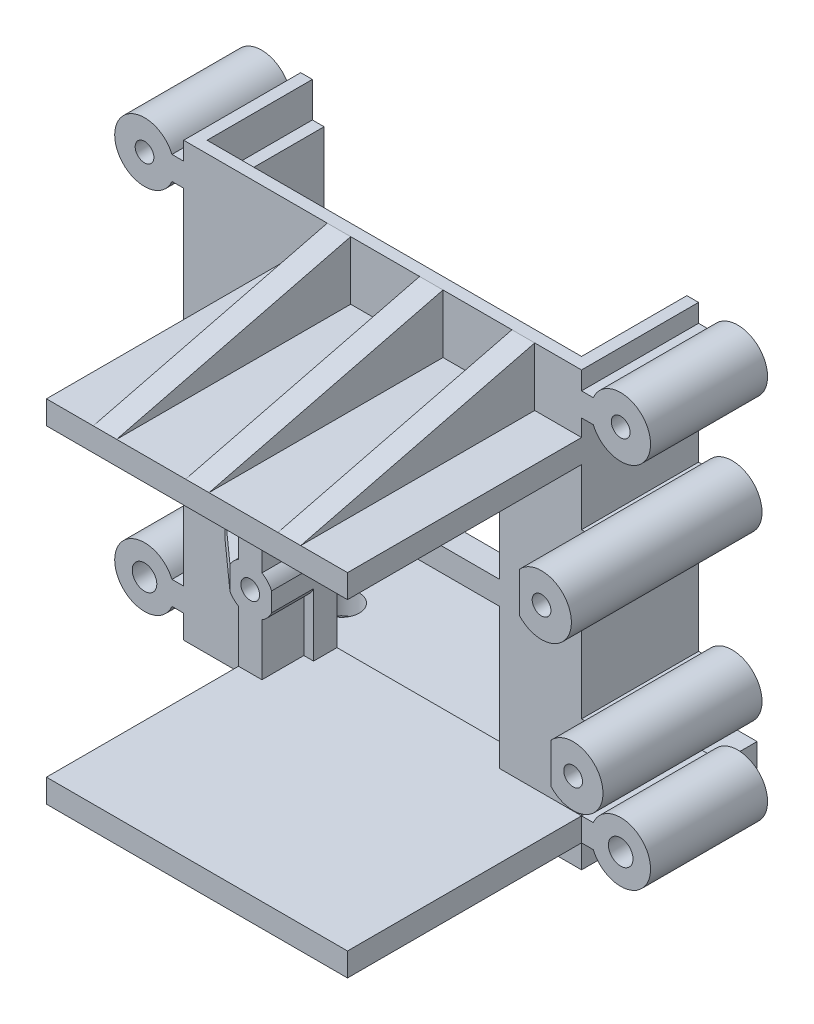
from build123d import *

# Parameters (mm, degrees)
ESQUISSE1_W              = 34
ESQUISSE1_H              = 15
BOSS_EXTRU_1_DEPTH       = 2
ESQUISSE2_R              = 1.5
ENL_V_MAT_EXTRU_1_DEPTH  = 2
BOSS_EXTRU_2_DEPTH       = 35
ENL_V_MAT_EXTRU_2_DEPTH  = 3
ESQUISSE5_R              = 3.5
ESQUISSE5_R_2            = 2
BOSS_EXTRU_3_DEPTH       = 3
ENL_V_START              = -2
ESQUISSE6_W              = 14
ESQUISSE6_H              = 12
ENL_V_MAT_EXTRU_3_DEPTH  = 2
ESQUISSE7_W              = 14
ESQUISSE7_H              = 12
ENL_V_MAT_EXTRU_4_DEPTH  = 2
ESQUISSE8_W              = 3
ESQUISSE8_H              = 12
ENL_V_MAT_EXTRU_5_DEPTH  = 2
BOSS_EXTRU_4_START       = -2
ESQUISSE9_W              = 1.1
ESQUISSE9_H              = 12
BOSS_EXTRU_4_DEPTH       = 2
ESQUISSE10_R             = 0.8
BOSS_EXTRU_5_DEPTH       = 6.285817
ESQUISSE11_R             = 0.8
BOSS_EXTRU_6_DEPTH       = 3.585817
ESQUISSE21_W             = 4
ESQUISSE21_H             = 2
BOSS_EXTRU_12_DEPTH      = 6.285817
ENL_V_MAT_EXTRU_9_DEPTH  = 2
ESQUISSE23_W             = 4
ESQUISSE23_H             = 2
BOSS_EXTRU_13_DEPTH      = 3.585817
ENL_V_MAT_EXTRU_10_DEPTH = 2
ESQUISSE25_W             = 2
ESQUISSE25_H             = 4.092832792
ESQUISSE25_H_2           = 4.443065592
BOSS_EXTRU_14_DEPTH      = 3.585817
ESQUISSE27_W             = 2
ESQUISSE27_H             = 4.092832792
ESQUISSE27_H_2           = 4
BOSS_EXTRU_15_DEPTH      = 6.285817
BOSS_EXTRU_17_START      = -10
ESQUISSE31_R             = 1.05
BOSS_EXTRU_17_DEPTH      = 10
BOSS_EXTRU_18_START      = -10
ESQUISSE33_R             = 0.8
BOSS_EXTRU_18_DEPTH      = 10
ESQUISSE34_R             = 0.8
BOSS_EXTRU_19_DEPTH      = 16.290743
ESQUISSE35_R             = 0.8
BOSS_EXTRU_20_DEPTH      = 13.590743
BOSS_EXTRU_21_DEPTH      = 20
ENL_V_START_2            = -17.727203
ENL_V_MAT_EXTRU_14_DEPTH = 17.727203
BOSS_EXTRU_23_START      = -2
ESQUISSE39_W             = 3.585817331
ESQUISSE39_H             = 2.443065592
BOSS_EXTRU_23_DEPTH      = 2
ENL_V_START_3            = -6.290743
ESQUISSE40_W             = 1.637082072
ESQUISSE40_H             = 4.811547665
ENL_V_MAT_EXTRU_15_DEPTH = 6.290743
ENL_V_START_4            = -3.590743
ESQUISSE41_W             = 1.862657742
ESQUISSE41_H             = 4.792301475
ENL_V_MAT_EXTRU_16_DEPTH = 3.590743
BOSS_EXTRU_24_DEPTH      = 20
ENL_V_MAT_EXTRU_17_DEPTH = 17.727203


with BuildPart() as part:
    # Esquisse1 → Boss.-Extru.1 (new body)
    with BuildSketch(Plane(origin=(0, 0, 0), x_dir=(1, 0, 0), z_dir=(0, 1, 0))):
        with Locations((17, 7.5)):
            Rectangle(ESQUISSE1_W, ESQUISSE1_H)
    extrude(amount=BOSS_EXTRU_1_DEPTH)

    # Esquisse2 → Enl_v. mat.-Extru.1 (cut)
    with BuildSketch(Plane(origin=(0, 2, 0), x_dir=(1, 0, 0), z_dir=(0, 1, 0))):
        with Locations((6, 7.5)):
            Circle(ESQUISSE2_R)
        with Locations((28, 7.5)):
            Circle(ESQUISSE2_R)
    extrude(amount=-ENL_V_MAT_EXTRU_1_DEPTH, mode=Mode.SUBTRACT)

    # Esquisse3 → Boss.-Extru.2 (add)
    with BuildSketch(Plane(origin=(0, 2, 0), x_dir=(1, 0, 0), z_dir=(0, 1, 0))):
        Polygon((0, 10), (2, 10), (2, 2), (32, 2), (32, 10), (34, 10), (34, 0), (0, 0), align=None)
    extrude(amount=BOSS_EXTRU_2_DEPTH)

    # Esquisse4 → Enl_v. mat.-Extru.2 (cut)
    with BuildSketch(Plane(origin=(0, 37, 0), x_dir=(1, 0, 0), z_dir=(0, 1, 0))):
        Polygon((2, 10), (1, 10), (1, 1), (33, 1), (33, 10), (32, 10), (32, 2), (2, 2), align=None)
    extrude(amount=-ENL_V_MAT_EXTRU_2_DEPTH, mode=Mode.SUBTRACT)

    # Esquisse5 → Boss.-Extru.3 (add)
    with BuildSketch(Plane.XZ):
        with Locations((6, -7.5)):
            Circle(ESQUISSE5_R)
        with Locations((6, -7.5)):
            Circle(ESQUISSE5_R_2, mode=Mode.SUBTRACT)
        with Locations((28, -7.5)):
            Circle(ESQUISSE5_R)
        with Locations((28, -7.5)):
            Circle(ESQUISSE5_R_2, mode=Mode.SUBTRACT)
    extrude(amount=BOSS_EXTRU_3_DEPTH)

    # Esquisse6 → Enl_v. mat.-Extru.3 (cut)
    with BuildSketch(Plane(origin=(0, 0, -2), x_dir=(-1, 0, 0), z_dir=(0, 0, -1)).offset(ENL_V_START)):
        with Locations((-17, 24)):
            Rectangle(ESQUISSE6_W, ESQUISSE6_H)
    extrude(amount=ENL_V_MAT_EXTRU_3_DEPTH, mode=Mode.SUBTRACT)

    # Esquisse7 → Enl_v. mat.-Extru.4 (cut)
    with BuildSketch(Plane(origin=(0, 0, -2), x_dir=(-1, 0, 0), z_dir=(0, 0, -1)).offset(ENL_V_START)):
        with Locations((-17, 10)):
            Rectangle(ESQUISSE7_W, ESQUISSE7_H)
    extrude(amount=ENL_V_MAT_EXTRU_4_DEPTH, mode=Mode.SUBTRACT)

    # Esquisse8 → Enl_v. mat.-Extru.5 (cut)
    with BuildSketch(Plane.XY.offset(ENL_V_START)):
        with Locations((25.5, 10)):
            Rectangle(ESQUISSE8_W, ESQUISSE8_H)
        with Locations((25.5, 24)):
            Rectangle(ESQUISSE8_W, ESQUISSE8_H)
    extrude(amount=ENL_V_MAT_EXTRU_5_DEPTH, mode=Mode.SUBTRACT)

    # Esquisse9 → Boss.-Extru.4 (add)
    with BuildSketch(Plane.XY.offset(BOSS_EXTRU_4_START)):
        with Locations((10.55, 24)):
            Rectangle(ESQUISSE9_W, ESQUISSE9_H)
        with Locations((10.55, 10)):
            Rectangle(ESQUISSE9_W, ESQUISSE9_H)
    extrude(amount=BOSS_EXTRU_4_DEPTH)

    # Esquisse10 → Boss.-Extru.5 (add)
    with BuildSketch(Plane.XY):
        with BuildLine():
            Line((11.1, 24.988338073), (11.1, 23.361894727))
            ThreePointArc((11.1, 23.361894727), (7.27279708, 24.1751164), (11.1, 24.988338073))
        make_face()
        with Locations((9.27279708, 24.1751164)):
            Circle(ESQUISSE10_R, mode=Mode.SUBTRACT)
    extrude(amount=BOSS_EXTRU_5_DEPTH)

    # Esquisse11 → Boss.-Extru.6 (add)
    with BuildSketch(Plane.XY):
        with BuildLine():
            Line((11.1, 10.988338073), (11.1, 9.361894727))
            ThreePointArc((11.1, 9.361894727), (7.27279708, 10.1751164), (11.1, 10.988338073))
        make_face()
        with Locations((9.27279708, 10.1751164)):
            Circle(ESQUISSE11_R, mode=Mode.SUBTRACT)
    extrude(amount=BOSS_EXTRU_6_DEPTH)

    # Esquisse21 → Boss.-Extru.12 (add)
    with BuildSketch(Plane.XY):
        with Locations((5.540746272, 24.1751164)):
            Rectangle(ESQUISSE21_W, ESQUISSE21_H)
    extrude(amount=BOSS_EXTRU_12_DEPTH)

    # Esquisse22 → Enl_v. mat.-Extru.9 (cut)
    with BuildSketch(Plane(origin=(0, 25.1751164, 0), x_dir=(1, 0, 0), z_dir=(0, 1, 0))):
        Polygon((3.540746272, 0), (7.540746272, -6.285817331), (3.540746272, -6.285817331), align=None)
    extrude(amount=-ENL_V_MAT_EXTRU_9_DEPTH, mode=Mode.SUBTRACT)

    # Esquisse23 → Boss.-Extru.13 (add)
    with BuildSketch(Plane.XY):
        with Locations((5.540746272, 10.1751164)):
            Rectangle(ESQUISSE23_W, ESQUISSE23_H)
    extrude(amount=BOSS_EXTRU_13_DEPTH)

    # Esquisse24 → Enl_v. mat.-Extru.10 (cut)
    with BuildSketch(Plane.XZ.offset(-9.1751164)):
        Polygon((7.540746272, 3.585817331), (3.540746272, 0), (3.540746272, 3.585817331), align=None)
    extrude(amount=-ENL_V_MAT_EXTRU_10_DEPTH, mode=Mode.SUBTRACT)

    # Esquisse25 → Boss.-Extru.14 (add)
    with BuildSketch(Plane.XY):
        with Locations((9.27279708, 13.953583604)):
            Rectangle(ESQUISSE25_W, ESQUISSE25_H)
        with Locations((9.27279708, 6.221532796)):
            Rectangle(ESQUISSE25_W, ESQUISSE25_H_2)
    extrude(amount=BOSS_EXTRU_14_DEPTH)

    # Esquisse27 → Boss.-Extru.15 (add)
    with BuildSketch(Plane.XY):
        with Locations((9.27279708, 27.953583604)):
            Rectangle(ESQUISSE27_W, ESQUISSE27_H)
        with Locations((9.27279708, 20.443065592)):
            Rectangle(ESQUISSE27_W, ESQUISSE27_H_2)
    extrude(amount=BOSS_EXTRU_15_DEPTH)

    # Esquisse31 → Boss.-Extru.17 (add)
    with BuildSketch(Plane.XY.offset(BOSS_EXTRU_17_START)):
        with BuildLine():
            Line((-1, 4), (0, 4))
            Line((0, 4), (0, 2))
            Line((0, 2), (-1, 2))
            ThreePointArc((-1, 2), (-5.895740821, 3), (-1, 4))
        make_face()
        with Locations((-3.345740821, 3)):
            Circle(ESQUISSE31_R, mode=Mode.SUBTRACT)
        with BuildLine():
            Line((34, 4), (34, 2))
            Line((34, 2), (35, 2))
            ThreePointArc((35, 2), (39.895740821, 3), (35, 4))
            Line((35, 4), (34, 4))
        make_face()
        with Locations((37.345740821, 3)):
            Circle(ESQUISSE31_R, mode=Mode.SUBTRACT)
    extrude(amount=BOSS_EXTRU_17_DEPTH)

    # Esquisse33 → Boss.-Extru.18 (add)
    with BuildSketch(Plane.XY.offset(BOSS_EXTRU_18_START)):
        with BuildLine():
            Line((35, 33.45), (34, 33.45))
            Line((34, 33.45), (34, 35.45))
            Line((34, 35.45), (35, 35.45))
            ThreePointArc((35, 35.45), (39.895740821, 34.45), (35, 33.45))
        make_face()
        with Locations((37.345740821, 34.45)):
            Circle(ESQUISSE33_R, mode=Mode.SUBTRACT)
        with BuildLine():
            Line((0, 33.45), (0, 35.45))
            Line((0, 35.45), (-1, 35.45))
            ThreePointArc((-1, 35.45), (-5.895740821, 34.45), (-1, 33.45))
            Line((-1, 33.45), (0, 33.45))
        make_face()
        with Locations((-3.345740821, 34.45)):
            Circle(ESQUISSE33_R, mode=Mode.SUBTRACT)
    extrude(amount=BOSS_EXTRU_18_DEPTH)

    # Esquisse34 → Boss.-Extru.19 (add)
    with BuildSketch(Plane(origin=(0, 0, -10), x_dir=(-1, 0, 0), z_dir=(0, 0, -1))):
        with BuildLine():
            Line((-34.527056259, 25.1751164), (-34, 25.1751164))
            Line((-34, 25.1751164), (-34, 23.1751164))
            Line((-34, 23.1751164), (-34.527056259, 23.1751164))
            ThreePointArc((-34.527056259, 23.1751164), (-39.42279708, 24.1751164), (-34.527056259, 25.1751164))
        make_face()
        with Locations((-36.87279708, 24.1751164)):
            Circle(ESQUISSE34_R, mode=Mode.SUBTRACT)
    extrude(amount=-BOSS_EXTRU_19_DEPTH)

    # Esquisse35 → Boss.-Extru.20 (add)
    with BuildSketch(Plane(origin=(0, 0, -10), x_dir=(-1, 0, 0), z_dir=(0, 0, -1))):
        with BuildLine():
            Line((-34.527056259, 11.1751164), (-34, 11.1751164))
            Line((-34, 11.1751164), (-34, 9.1751164))
            Line((-34, 9.1751164), (-34.527056259, 9.1751164))
            ThreePointArc((-34.527056259, 9.1751164), (-39.42279708, 10.1751164), (-34.527056259, 11.1751164))
        make_face()
        with Locations((-36.87279708, 10.1751164)):
            Circle(ESQUISSE35_R, mode=Mode.SUBTRACT)
    extrude(amount=-BOSS_EXTRU_20_DEPTH)

    # Esquisse36 → Boss.-Extru.21 (add)
    with BuildSketch(Plane.XY):
        Polygon((8.27279708, 30), (34, 30), (34, 32), (30, 32), (30, 37), (28.05279708, 37), (28.05279708, 32), (22.16279708, 32), (22.16279708, 37), (20.16279708, 37), (20.16279708, 32), (14.27279708, 32), (14.27279708, 37), (12.27279708, 37), (12.27279708, 32), (8.27279708, 32), align=None)
    extrude(amount=BOSS_EXTRU_21_DEPTH)

    # Esquisse37 → Enl_v. mat.-Extru.14 (cut)
    with BuildSketch(Plane(origin=(30, 0, 0), x_dir=(0, 0, -1), z_dir=(1, 0, 0)).offset(ENL_V_START_2)):
        Polygon((-20, 32), (0, 37), (-20, 37), align=None)
    extrude(amount=ENL_V_MAT_EXTRU_14_DEPTH, mode=Mode.SUBTRACT)

    # Esquisse39 → Boss.-Extru.23 (add)
    with BuildSketch(Plane.ZY.offset(-8.27279708).offset(BOSS_EXTRU_23_START)):
        with Locations((1.792908666, 17.221532796)):
            Rectangle(ESQUISSE39_W, ESQUISSE39_H)
    extrude(amount=BOSS_EXTRU_23_DEPTH)

    # Esquisse40 → Enl_v. mat.-Extru.15 (cut)
    with BuildSketch(Plane.XY.offset(6.290743087).offset(ENL_V_START_3)):
        with Locations((34.181130377, 24.126818711)):
            Rectangle(ESQUISSE40_W, ESQUISSE40_H)
    extrude(amount=ENL_V_MAT_EXTRU_15_DEPTH, mode=Mode.SUBTRACT)

    # Esquisse41 → Enl_v. mat.-Extru.16 (cut)
    with BuildSketch(Plane.XY.offset(3.590743087).offset(ENL_V_START_4)):
        with Locations((34.068342542, 10.376328553)):
            Rectangle(ESQUISSE41_W, ESQUISSE41_H)
    extrude(amount=ENL_V_MAT_EXTRU_16_DEPTH, mode=Mode.SUBTRACT)

    # Esquisse43 → Boss.-Extru.24 (add)
    with BuildSketch(Plane.XY):
        Polygon((14.27279708, 2), (20.16279708, 2), (20.16279708, 0), (22.16279708, 0), (22.16279708, 2), (28, 2), (28, 0), (30, 0), (30, 2), (34, 2), (34, 4), (8.27279708, 4), (8.27279708, 2), (12.27279708, 2), (12.27279708, 0), (14.27279708, 0), align=None)
    extrude(amount=BOSS_EXTRU_24_DEPTH)

    # Esquisse44 → Enl_v. mat.-Extru.17 (cut)
    with BuildSketch(Plane.ZY.offset(-12.27279708).offset(ENL_V_START_2)):
        Polygon((20, 2), (0, 0), (20, 0), align=None)
    extrude(amount=ENL_V_MAT_EXTRU_17_DEPTH, mode=Mode.SUBTRACT)


solid = part.part
